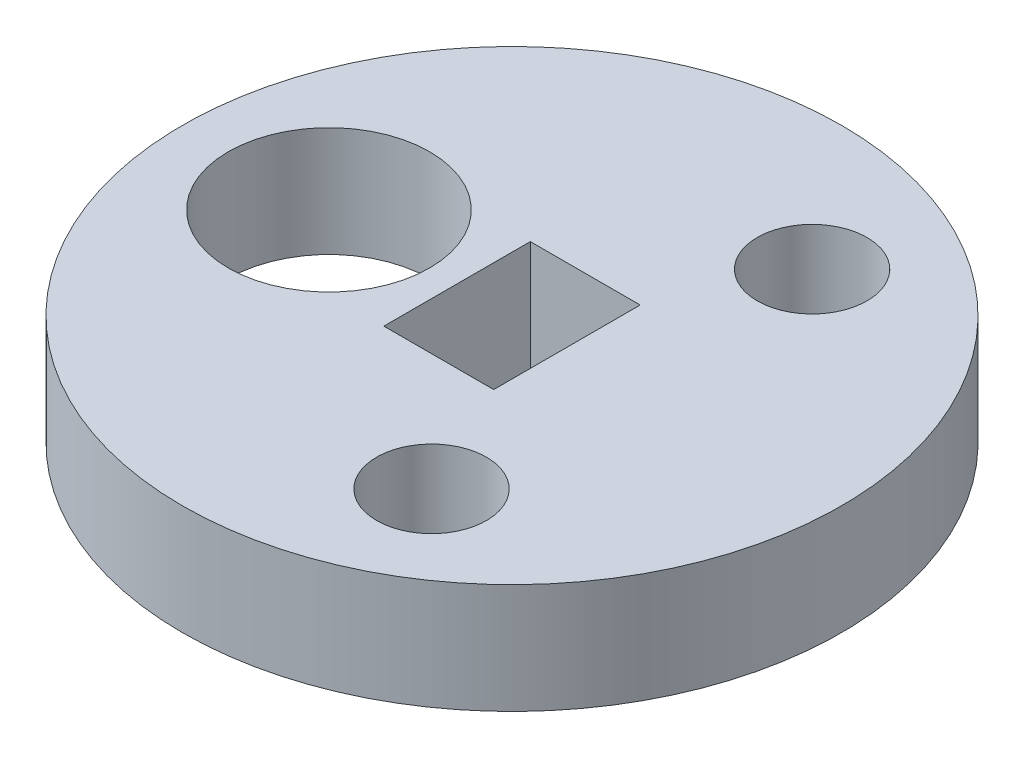
from build123d import *

# Parameters (mm, degrees)
SKETCH1_R           = 9
SKETCH1_R_2         = 2.75
SKETCH1_R_3         = 1.5
SKETCH1_W           = 3
SKETCH1_H           = 4
BOSS_EXTRUDE1_DEPTH = 3


with BuildPart() as part:
    # Sketch1 → Boss-Extrude1 (new body)
    with BuildSketch(Plane(origin=(0, 0, 0), x_dir=(1, 0, 0), z_dir=(0, 1, 0))):
        Circle(SKETCH1_R)
        with Locations((-5, 0.000835232)):
            Circle(SKETCH1_R_2, mode=Mode.SUBTRACT)
        with Locations((2.999131959, -5.19665349)):
            Circle(SKETCH1_R_3, mode=Mode.SUBTRACT)
        with Locations((3.000867957, 5.195651211)):
            Circle(SKETCH1_R_3, mode=Mode.SUBTRACT)
        Rectangle(SKETCH1_W, SKETCH1_H, mode=Mode.SUBTRACT)
    extrude(amount=BOSS_EXTRUDE1_DEPTH)


solid = part.part
